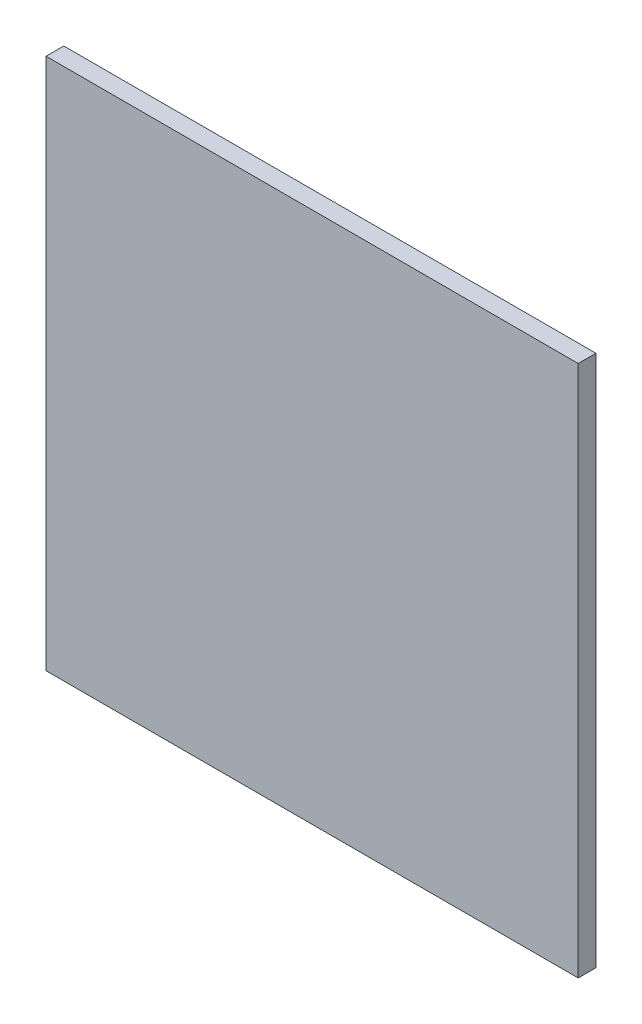
from build123d import *

# Parameters (mm, degrees)
SKETCH1_W           = 762
SKETCH1_H           = 762
BOSS_EXTRUDE1_DEPTH = 25.4


with BuildPart() as part:
    # Sketch1 → Boss-Extrude1 (new body)
    with BuildSketch(Plane.XY):
        with Locations((381, 381)):
            Rectangle(SKETCH1_W, SKETCH1_H)
    extrude(amount=BOSS_EXTRUDE1_DEPTH)


solid = part.part
